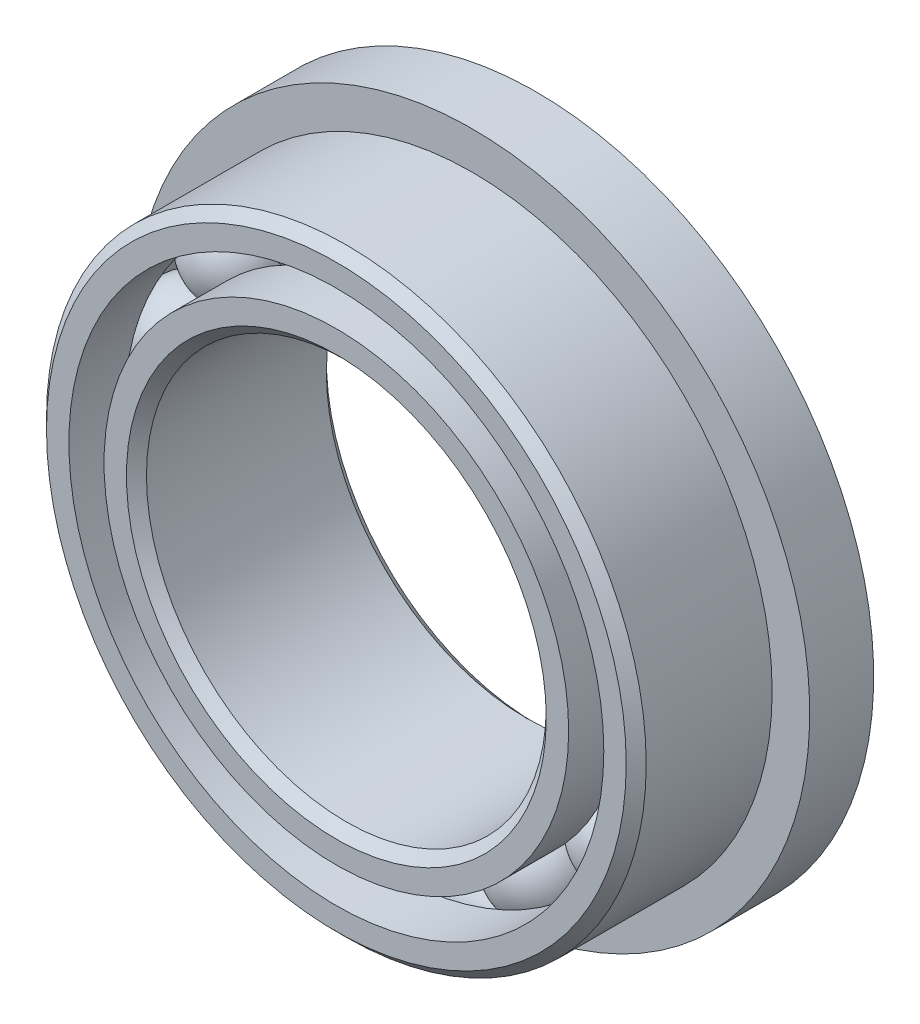
from build123d import *

# Parameters (mm, degrees)
SKETCH5_W         = 1.016
SKETCH5_H         = 0.93358956
CIRPATTERN1_COUNT = 14


with BuildPart() as part:
    # Sketch1 → Revolve1 (revolve)
    with BuildSketch(Plane(origin=(0, 0, 0), x_dir=(0, 0, -1), z_dir=(1, 0, 0))):
        with BuildLine():
            Line((1.42875, 4.7625), (-1.42875, 4.7625))
            Line((-1.42875, 4.7625), (-1.5875, 4.60375))
            Line((-1.5875, 4.60375), (-1.5875, 4.247870879))
            Line((-1.5875, 4.247870879), (-0.705555556, 4.247870879))
            ThreePointArc((-0.705555556, 4.247870879), (0, 4.727510244), (0.705555556, 4.247870879))
            Line((0.705555556, 4.247870879), (1.5875, 4.247870879))
            Line((1.5875, 4.247870879), (1.5875, 4.60375))
            Line((1.5875, 4.60375), (1.42875, 4.7625))
        make_face()
    revolve(axis=Axis((0, 0, 1.5875), (0, 0, -1)))

    # Sketch5 → Revolve5 (revolve)
    with BuildSketch(Plane(origin=(0, 0, 0), x_dir=(0, 0, -1), z_dir=(1, 0, 0))):
        with Locations((1.0795, 4.89260522)):
            Rectangle(SKETCH5_W, SKETCH5_H)
    revolve(axis=Axis((0, 0, -1.5875), (0, 0, 1)))


with BuildPart() as body_2:
    # Sketch3 → Revolve3 (revolve)
    with BuildSketch(Plane(origin=(0, 0, 0), x_dir=(0, 0, -1), z_dir=(1, 0, 0))):
        with BuildLine():
            Line((-0.705555556, 3.689629121), (-1.5875, 3.689629121))
            Line((-1.5875, 3.689629121), (-1.5875, 3.33375))
            Line((-1.5875, 3.33375), (-1.42875, 3.175))
            Line((-1.42875, 3.175), (1.42875, 3.175))
            Line((1.42875, 3.175), (1.5875, 3.33375))
            Line((1.5875, 3.33375), (1.5875, 3.689629121))
            Line((1.5875, 3.689629121), (0.705555556, 3.689629121))
            ThreePointArc((0.705555556, 3.689629121), (0, 3.209989756), (-0.705555556, 3.689629121))
        make_face()
    revolve(axis=Axis((0, 0, 1.5875), (0, 0, -1)))


with BuildPart() as body_3:
    # Sketch4 → Revolve4 (revolve)
    with BuildSketch(Plane(origin=(0, 0, 0), x_dir=(0, 0, -1), z_dir=(1, 0, 0))):
        with BuildLine():
            Line((-0.758760244, 3.96875), (0.758760244, 3.96875))
            ThreePointArc((0.758760244, 3.96875), (0, 4.727510244), (-0.758760244, 3.96875))
        make_face()
    revolve(axis=Axis((0, 3.96875, 0.758760244), (0, 0, -1)))


with BuildPart() as cirpattern1_1:
    # CirPattern1: pattern copy
    add(body_3.part.rotate(Axis((0, 0, -1.5875), (0, 0, 1)), 1 * 360 / CIRPATTERN1_COUNT))


with BuildPart() as cirpattern1_2:
    # CirPattern1: pattern copy
    add(body_3.part.rotate(Axis((0, 0, -1.5875), (0, 0, 1)), 2 * 360 / CIRPATTERN1_COUNT))


with BuildPart() as cirpattern1_3:
    # CirPattern1: pattern copy
    add(body_3.part.rotate(Axis((0, 0, -1.5875), (0, 0, 1)), 3 * 360 / CIRPATTERN1_COUNT))


with BuildPart() as cirpattern1_4:
    # CirPattern1: pattern copy
    add(body_3.part.rotate(Axis((0, 0, -1.5875), (0, 0, 1)), 4 * 360 / CIRPATTERN1_COUNT))


with BuildPart() as cirpattern1_5:
    # CirPattern1: pattern copy
    add(body_3.part.rotate(Axis((0, 0, -1.5875), (0, 0, 1)), 5 * 360 / CIRPATTERN1_COUNT))


with BuildPart() as cirpattern1_6:
    # CirPattern1: pattern copy
    add(body_3.part.rotate(Axis((0, 0, -1.5875), (0, 0, 1)), 6 * 360 / CIRPATTERN1_COUNT))


with BuildPart() as cirpattern1_7:
    # CirPattern1: pattern copy
    add(body_3.part.rotate(Axis((0, 0, -1.5875), (0, 0, 1)), 7 * 360 / CIRPATTERN1_COUNT))


with BuildPart() as cirpattern1_8:
    # CirPattern1: pattern copy
    add(body_3.part.rotate(Axis((0, 0, -1.5875), (0, 0, 1)), 8 * 360 / CIRPATTERN1_COUNT))


with BuildPart() as cirpattern1_9:
    # CirPattern1: pattern copy
    add(body_3.part.rotate(Axis((0, 0, -1.5875), (0, 0, 1)), 9 * 360 / CIRPATTERN1_COUNT))


with BuildPart() as cirpattern1_10:
    # CirPattern1: pattern copy
    add(body_3.part.rotate(Axis((0, 0, -1.5875), (0, 0, 1)), 10 * 360 / CIRPATTERN1_COUNT))


with BuildPart() as cirpattern1_11:
    # CirPattern1: pattern copy
    add(body_3.part.rotate(Axis((0, 0, -1.5875), (0, 0, 1)), 11 * 360 / CIRPATTERN1_COUNT))


with BuildPart() as cirpattern1_12:
    # CirPattern1: pattern copy
    add(body_3.part.rotate(Axis((0, 0, -1.5875), (0, 0, 1)), 12 * 360 / CIRPATTERN1_COUNT))


with BuildPart() as cirpattern1_13:
    # CirPattern1: pattern copy
    add(body_3.part.rotate(Axis((0, 0, -1.5875), (0, 0, 1)), 13 * 360 / CIRPATTERN1_COUNT))


solid = Compound([part.part, body_2.part, body_3.part, cirpattern1_1.part, cirpattern1_2.part, cirpattern1_3.part, cirpattern1_4.part, cirpattern1_5.part, cirpattern1_6.part, cirpattern1_7.part, cirpattern1_8.part, cirpattern1_9.part, cirpattern1_10.part, cirpattern1_11.part, cirpattern1_12.part, cirpattern1_13.part])
